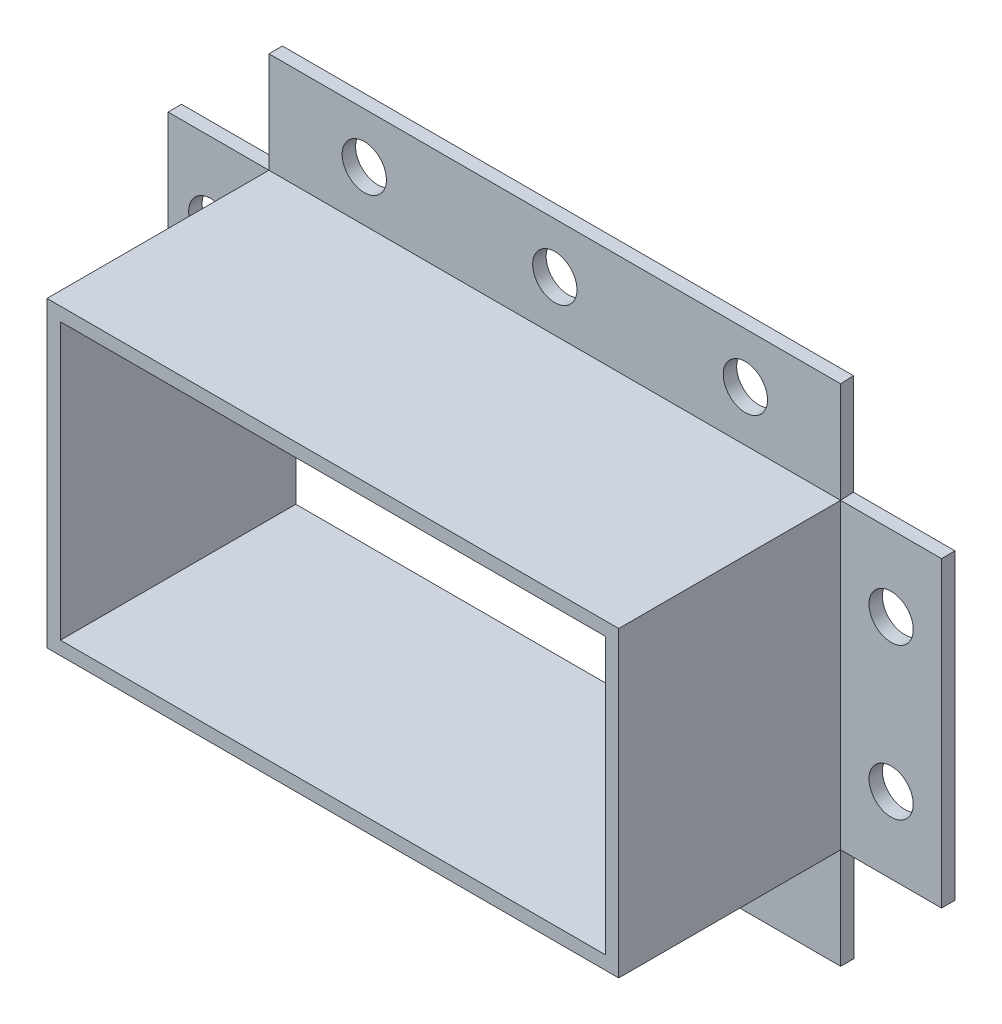
from build123d import *

# Parameters (mm, degrees)
ESBO_O1_W                                      = 85
ESBO_O1_H                                      = 45
RESSALTO_EXTRUS_O1_DEPTH                       = 35
ESBO_O2_W                                      = 81
ESBO_O2_H                                      = 41
CORTE_EXTRUS_O1_DEPTH                          = 33
ESBO_O3_W                                      = 2
ESBO_O3_H                                      = 45
RESSALTO_EXTRUS_O2_DEPTH                       = 15
RESSALTO_EXTRUS_O3_DEPTH                       = 15
ESBO_O5_W                                      = 2
ESBO_O5_H                                      = 45
RESSALTO_EXTRUS_O4_DEPTH                       = 15
ESBO_O6_W                                      = 85
ESBO_O6_H                                      = 2
RESSALTO_EXTRUS_O5_DEPTH                       = 15
BROCA_DE_ROSQUEAR_DE_CANO_PARA_TARRAXA_D_D     = 6.579997
BROCA_DE_ROSQUEAR_DE_CANO_PARA_TARRAXA_D_DEPTH = 10
BROCA_DE_ROSQUEAR_DE_CANO_PARA_TARRAXA_D_TIP   = 1.976830535
CORTE_EXTRUS_O2_REACH                          = 37
ESBO_O9_W                                      = 81
ESBO_O9_H                                      = 41


with BuildPart() as part:
    # Esboço1 → Ressalto-extrusão1 (new body)
    with BuildSketch(Plane.XY):
        Rectangle(ESBO_O1_W, ESBO_O1_H)
    extrude(amount=RESSALTO_EXTRUS_O1_DEPTH)

    # Esboço2 → Corte-extrusão1 (cut)
    with BuildSketch(Plane(origin=(0, 0, 0), x_dir=(-1, 0, 0), z_dir=(0, 0, -1))):
        Rectangle(ESBO_O2_W, ESBO_O2_H)
    extrude(amount=-CORTE_EXTRUS_O1_DEPTH, mode=Mode.SUBTRACT)

    # Esboço3 → Ressalto-extrusão2 (add)
    with BuildSketch(Plane(origin=(42.5, 0, 0), x_dir=(0, 0, -1), z_dir=(1, 0, 0))):
        with Locations((-1, 0)):
            Rectangle(ESBO_O3_W, ESBO_O3_H)
    extrude(amount=RESSALTO_EXTRUS_O2_DEPTH)

    # Esboço4 → Ressalto-extrusão3 (add)
    with BuildSketch(Plane(origin=(0, 22.5, 0), x_dir=(1, 0, 0), z_dir=(0, 1, 0))):
        Polygon((42.397707887, 0), (42.5, -2), (-42.5, -2), (-42.5, 0), align=None)
    extrude(amount=RESSALTO_EXTRUS_O3_DEPTH)

    # Esboço5 → Ressalto-extrusão4 (add)
    with BuildSketch(Plane.ZY.offset(42.5)):
        with Locations((1, 0)):
            Rectangle(ESBO_O5_W, ESBO_O5_H)
    extrude(amount=RESSALTO_EXTRUS_O4_DEPTH)

    # Esboço6 → Ressalto-extrusão5 (add)
    with BuildSketch(Plane.XZ.offset(22.5)):
        with Locations((0, 1)):
            Rectangle(ESBO_O6_W, ESBO_O6_H)
    extrude(amount=RESSALTO_EXTRUS_O5_DEPTH)

    # Broca de rosquear de cano para tarraxa de 1/81
    with Locations(Plane.XY.offset(2)):
        with Locations((50, 11.25), (50, -11.25), (-51.152400613, -11.25), (-51.152400613, 11.25), (-28.33, 30), (0, 30), (28.33, 30), (28.33, -30), (0, -30), (-28.33, -30)):
            Hole(BROCA_DE_ROSQUEAR_DE_CANO_PARA_TARRAXA_D_D / 2, depth=BROCA_DE_ROSQUEAR_DE_CANO_PARA_TARRAXA_D_DEPTH)
            with Locations((0, 0, -(BROCA_DE_ROSQUEAR_DE_CANO_PARA_TARRAXA_D_DEPTH + BROCA_DE_ROSQUEAR_DE_CANO_PARA_TARRAXA_D_TIP / 2))):  # 118° drill point
                Cone(0, BROCA_DE_ROSQUEAR_DE_CANO_PARA_TARRAXA_D_D / 2, BROCA_DE_ROSQUEAR_DE_CANO_PARA_TARRAXA_D_TIP, mode=Mode.SUBTRACT)

    # Esboço9 → Corte-extrusão2 (cut, up to next)
    with BuildSketch(Plane.XY.offset(35), mode=Mode.PRIVATE) as corte_extrus_o2_sk1:
        Rectangle(ESBO_O9_W, ESBO_O9_H)
    corte_extrus_o2_tool1 = extrude(corte_extrus_o2_sk1.sketch, amount=-CORTE_EXTRUS_O2_REACH, mode=Mode.PRIVATE) & part.part
    add(corte_extrus_o2_tool1.solids().sort_by_distance((0, 0, 35))[0], mode=Mode.SUBTRACT)


solid = part.part
